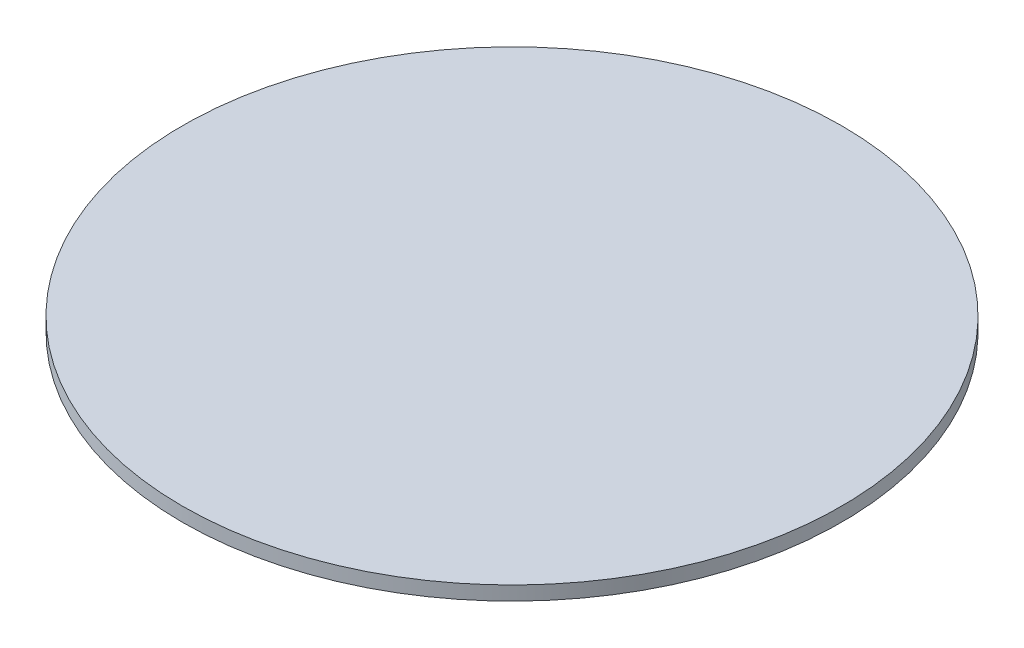
from build123d import *

# Parameters (mm, degrees)
SKETCH1_R           = 40
BOSS_EXTRUDE1_DEPTH = 1.7
SCALE2_SCALE        = 0.5


with BuildPart() as part:
    # Sketch1 → Boss-Extrude1 (new body)
    with BuildSketch(Plane(origin=(0, 0, 0), x_dir=(1, 0, 0), z_dir=(0, 1, 0))):
        Circle(SKETCH1_R)
    extrude(amount=BOSS_EXTRUDE1_DEPTH)


with BuildPart() as part_1:
    # Scale2: scaled about (0, 0.85, 0)
    add(part.part.scale(SCALE2_SCALE).moved(Location((0, 0.425, 0))))


solid = part_1.part
